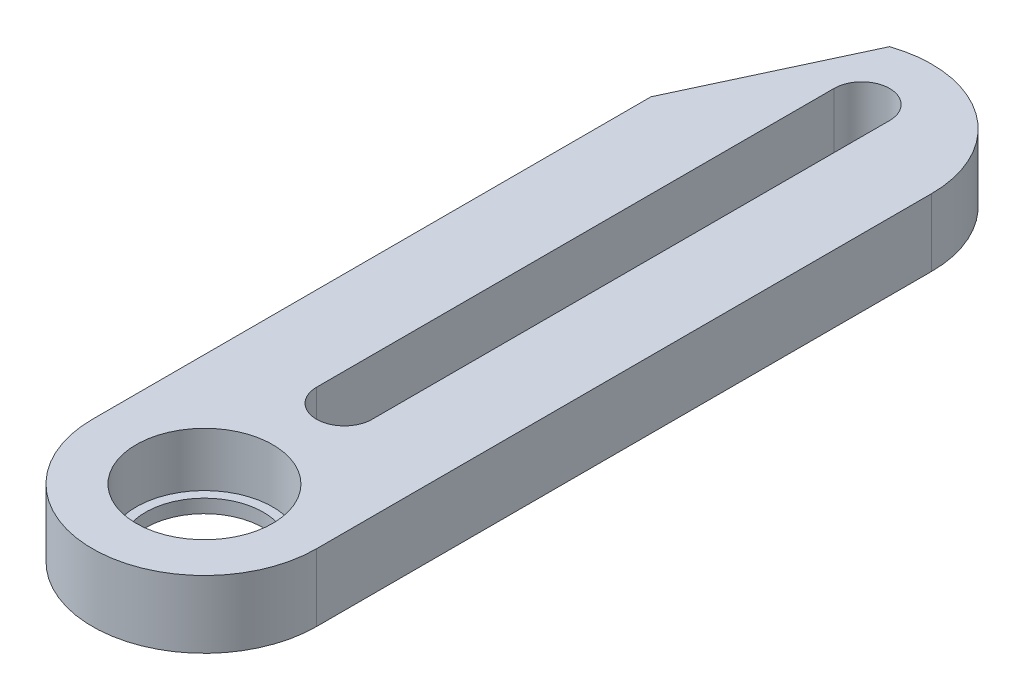
from build123d import *

# Parameters (mm, degrees)
SKETCH1_R           = 6.65
SKETCH1_R_2         = 4.05
BOSS_EXTRUDE1_DEPTH = 4
SKETCH2_R           = 4.05
BOSS_EXTRUDE2_DEPTH = 0.8
SKETCH3_R           = 3.5
CUT_EXTRUDE1_DEPTH  = 1.8
CUT_EXTRUDE2_DEPTH  = 5


with BuildPart() as part:
    # Sketch1 → Boss-Extrude1 (new body)
    with BuildSketch(Plane(origin=(0, 0, 0), x_dir=(1, 0, 0), z_dir=(0, 1, 0))):
        with BuildLine():
            Line((-6.65, 36.5), (-6.65, 0))
            ThreePointArc((-6.65, 0), (-4.702260096, 4.702260094), (-2e-09, 6.65))
            ThreePointArc((-2e-09, 6.65), (4.702260094, 4.702260096), (6.65, 0))
            Line((6.65, 0), (6.65, 36.5))
            ThreePointArc((6.65, 36.5), (0, 43.15), (-6.65, 36.5))
        make_face()
        with BuildLine():
            ThreePointArc((1.65, 8.3), (1.166726188, 7.13327381), (-2e-09, 6.65))
            ThreePointArc((-2e-09, 6.65), (-1.16672619, 7.133273812), (-1.65, 8.3))
            Line((-1.65, 8.3), (-1.65, 39))
            ThreePointArc((-1.65, 39), (0, 40.65), (1.65, 39))
            Line((1.65, 39), (1.65, 8.3))
        make_face(mode=Mode.SUBTRACT)
        Circle(SKETCH1_R)
        Circle(SKETCH1_R_2, mode=Mode.SUBTRACT)
    extrude(amount=BOSS_EXTRUDE1_DEPTH)

    # Sketch2 → Boss-Extrude2 (add)
    with BuildSketch(Plane(origin=(0, 0, 0), x_dir=(1, 0, 0), z_dir=(0, 1, 0))):
        Circle(SKETCH2_R)
    extrude(amount=BOSS_EXTRUDE2_DEPTH)

    # Sketch3 → Cut-Extrude1 (cut, through all)
    with BuildSketch(Plane(origin=(0, 0.8, 0), x_dir=(1, 0, 0), z_dir=(0, 1, 0))):
        Circle(SKETCH3_R)
    extrude(amount=-CUT_EXTRUDE1_DEPTH, mode=Mode.SUBTRACT)

    # Sketch4 → Cut-Extrude2 (cut, through all)
    with BuildSketch(Plane.XZ):
        with BuildLine():
            Line((-6.65, -33.142571947), (-2.15, -42.792853089))
            ThreePointArc((-2.15, -42.792853089), (-5.409251335, -40.368139087), (-6.65, -36.5))
            Line((-6.65, -36.5), (-6.65, -33.142571947))
        make_face()
    extrude(amount=-CUT_EXTRUDE2_DEPTH, mode=Mode.SUBTRACT)


solid = part.part
